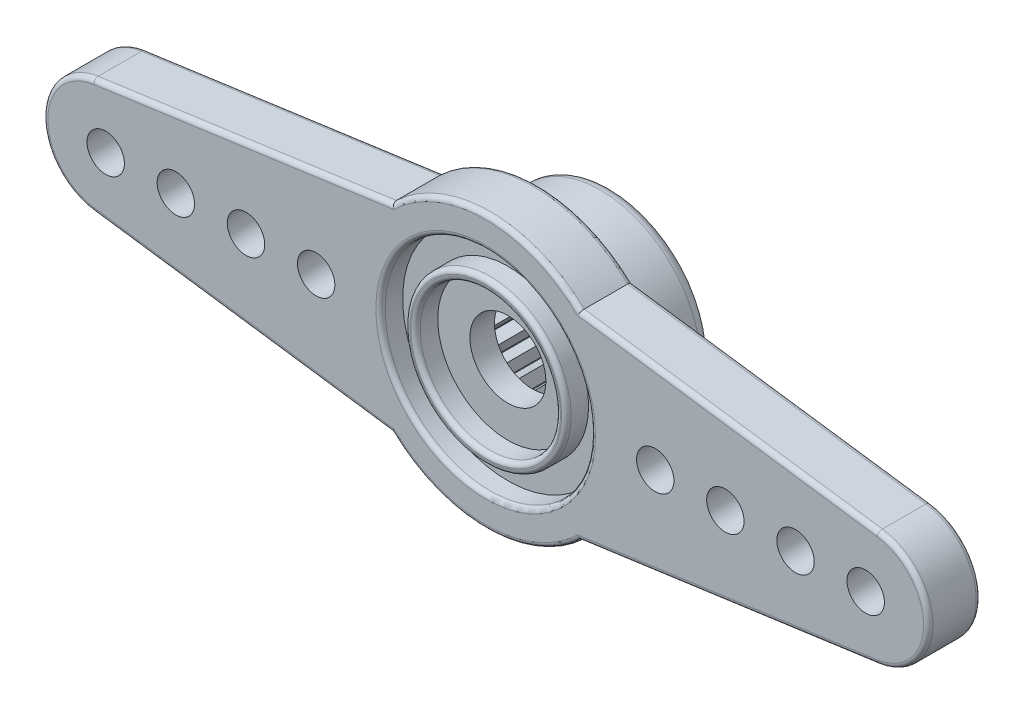
from build123d import *

# Parameters (mm, degrees)
SKETCH_1_R               = 4.3
EXTRUDE_1_DEPTH          = 2.7
EXTRUDE_2_DEPTH          = 2.25
SKETCH_3_R               = 4.5
SKETCH_3_R_2             = 3.45
SKETCH_3_R_3             = 3
CUT_EXTRUDE_1_DEPTH      = 0.95
FILLET_1_R               = 0.2
FILLET_2_R               = 0.5
SKETCH_4_R               = 1.625
CUT_EXTRUDE_2_DEPTH      = 21.302232164
SKETCH_5_R               = 2.9
CUT_EXTRUDE_3_DEPTH      = 3.4
EXTRUDE_3_DEPTH          = 3.4
PATTERN_CIRCULAR_1_COUNT = 25
SKETCH_9_R               = 0.8
CUT_EXTRUDE_7_DEPTH      = 2.25


with BuildPart() as part:
    # Эскиз1 → Бобышка-Вытянуть1 (new, symmetric)
    with BuildSketch(Plane.XY):
        with Locations(Location((0, 0, 0), (0, 0, 180))):
            Circle(SKETCH_1_R)
    extrude(amount=EXTRUDE_1_DEPTH, both=True)

    # Эскиз2 → Бобышка-Вытянуть2 (add)
    with BuildSketch(Plane.XY.offset(2.7)):
        with BuildLine():
            Line((-16.769507591, 2.476149131), (-4.019950248, 4.25))
            ThreePointArc((-4.019950248, 4.25), (0, 5.85), (4.019950248, 4.25))
            Line((4.019950248, 4.25), (16.769507591, 2.476149131))
            ThreePointArc((16.769507591, 2.476149131), (18.925, 0), (16.769507591, -2.476149131))
            Line((16.769507591, -2.476149131), (4.019950248, -4.25))
            ThreePointArc((4.019950248, -4.25), (0, -5.85), (-4.019950248, -4.25))
            Line((-4.019950248, -4.25), (-16.769507591, -2.476149131))
            ThreePointArc((-16.769507591, -2.476149131), (-18.925, 0), (-16.769507591, 2.476149131))
        make_face()
    extrude(amount=-EXTRUDE_2_DEPTH)

    # Эскиз3 → Вырез-Вытянуть1 (cut)
    with BuildSketch(Plane.XY.offset(2.7)):
        Circle(SKETCH_3_R)
        Circle(SKETCH_3_R_2, mode=Mode.SUBTRACT)
        Circle(SKETCH_3_R_3)
    extrude(amount=-CUT_EXTRUDE_1_DEPTH, mode=Mode.SUBTRACT)

    # Скругление1
    fillet_1_edges = [part.edges().sort_by_distance(p)[0] for p in [
        (0, -5.85, 2.7),
        (10.39472892, -3.363074566, 2.7),
        (18.925, 0, 2.7),
        (10.39472892, 3.363074566, 2.7),
        (0, 5.85, 2.7),
        (-10.39472892, 3.363074566, 2.7),
        (-3.45, 0, 2.7),
        (-4.5, 0, 2.7),
        (-3, 0, 2.7),
        (4.3, 0, 0.45),
        (-18.925, 0, 0.45),
        (-10.39472892, 3.363074566, 0.45),
        (0, 5.85, 0.45),
        (10.39472892, 3.363074566, 0.45),
        (18.925, 0, 0.45),
        (10.39472892, -3.363074566, 0.45),
        (0, -5.85, 0.45),
        (-10.39472892, -3.363074566, 0.45),
        (-18.925, 0, 2.7),
        (-10.39472892, -3.363074566, 2.7),
    ]]
    fillet(fillet_1_edges, radius=FILLET_1_R)

    # Скругление2
    fillet_2_edges = [part.edges().sort_by_distance(p)[0] for p in [
        (4.3, 0, -2.7),
    ]]
    fillet(fillet_2_edges, radius=FILLET_2_R)

    # Эскиз4 → Вырез-Вытянуть2 (cut, through all)
    with BuildSketch(Plane.XY.offset(1.75)):
        Circle(SKETCH_4_R)
    extrude(amount=-CUT_EXTRUDE_2_DEPTH, mode=Mode.SUBTRACT)

    # Эскиз5 → Вырез-Вытянуть3 (cut)
    with BuildSketch(Plane(origin=(0, 0, -2.7), x_dir=(-1, 0, 0), z_dir=(0, 0, -1))):
        Circle(SKETCH_5_R)
    extrude(amount=-CUT_EXTRUDE_3_DEPTH, mode=Mode.SUBTRACT)

    # Эскиз8 → Бобышка-Вытянуть3 (add)
    with BuildSketch(Plane(origin=(0, 0, -2.7), x_dir=(-1, 0, 0), z_dir=(0, 0, -1))):
        with BuildLine():
            Line((0.35, -2.878801834), (0, -2.4))
            Line((0, -2.4), (-0.35, -2.878801834))
            ThreePointArc((-0.35, -2.878801834), (0, -2.9), (0.35, -2.878801834))
        make_face()
    extrude_3 = extrude(amount=-EXTRUDE_3_DEPTH)

    # Круговой массив1: Бобышка-Вытянуть3 ×25 about axis
    pattern_circular_1_axis = Axis((0, 0, 0), (0, 0, 1))
    for i in range(1, PATTERN_CIRCULAR_1_COUNT):
        add(extrude_3.rotate(pattern_circular_1_axis, i * 360 / PATTERN_CIRCULAR_1_COUNT))

    # Эскиз9 → Вырез-Вытянуть7 (cut)
    with BuildSketch(Plane.XY.offset(2.7)):
        with Locations((7.25, 0)):
            Circle(SKETCH_9_R)
        with Locations((10.25, 0)):
            Circle(SKETCH_9_R)
        with Locations((13.25, 0)):
            Circle(SKETCH_9_R)
        with Locations((16.25, 0)):
            Circle(SKETCH_9_R)
    cut_extrude_7 = extrude(amount=-CUT_EXTRUDE_7_DEPTH, mode=Mode.SUBTRACT)

    # Зеркальное отражение1: Вырез-Вытянуть7 across plane
    add(cut_extrude_7.mirror(Plane(origin=(0, 0, 0), x_dir=(0, 0, 1), z_dir=(1, 0, 0))), mode=Mode.SUBTRACT)


solid = part.part
